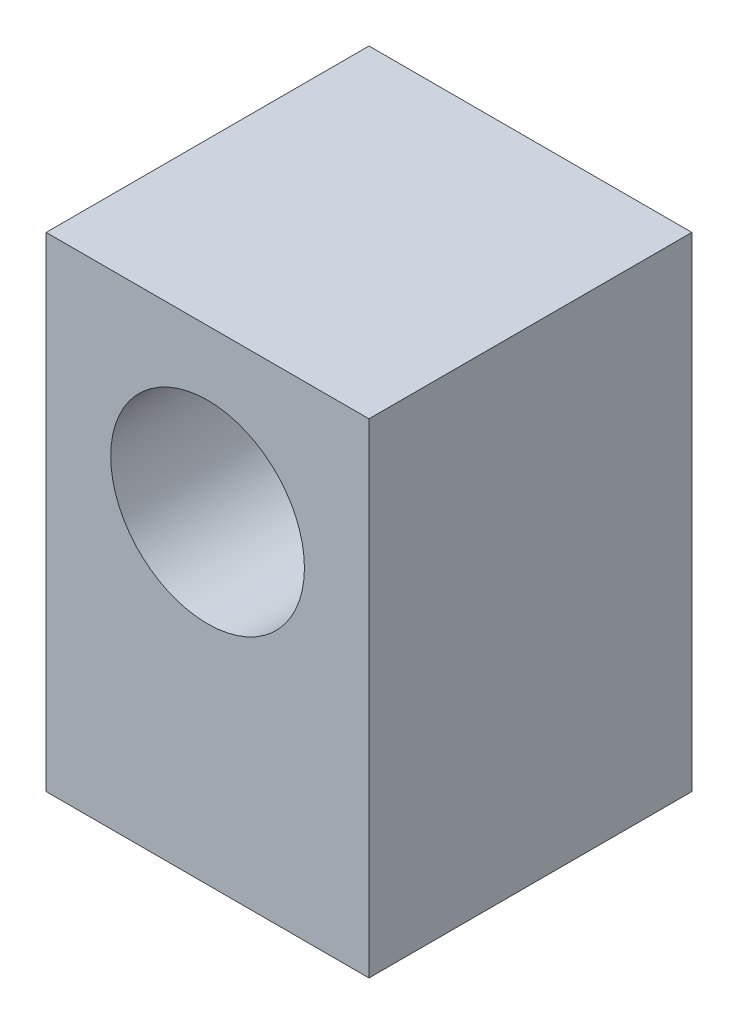
from build123d import *

# Parameters (mm, degrees)
SKETCH1_W           = 20
SKETCH1_H           = 20
BOSS_EXTRUDE2_DEPTH = 30
CUT_EXTRUDE1_REACH  = 22
SKETCH2_R           = 6
SKETCH3_R           = 5
CUT_EXTRUDE2_DEPTH  = 8


with BuildPart() as part:
    # Sketch1 → Boss-Extrude2 (new body)
    with BuildSketch(Plane(origin=(0, 0, 0), x_dir=(1, 0, 0), z_dir=(0, 1, 0))):
        Rectangle(SKETCH1_W, SKETCH1_H)
    extrude(amount=BOSS_EXTRUDE2_DEPTH)

    # Sketch2 → Cut-Extrude1 (cut, up to next)
    with BuildSketch(Plane.XY.offset(10), mode=Mode.PRIVATE) as cut_extrude1_sk1:
        with Locations((0, 20)):
            Circle(SKETCH2_R)
    cut_extrude1_tool1 = extrude(cut_extrude1_sk1.sketch, amount=-CUT_EXTRUDE1_REACH, mode=Mode.PRIVATE) & part.part
    add(cut_extrude1_tool1.solids().sort_by_distance((0, 20, 10))[0], mode=Mode.SUBTRACT)

    # Sketch3 → Cut-Extrude2 (cut)
    with BuildSketch(Plane.XZ):
        Circle(SKETCH3_R)
    extrude(amount=-CUT_EXTRUDE2_DEPTH, mode=Mode.SUBTRACT)


solid = part.part
